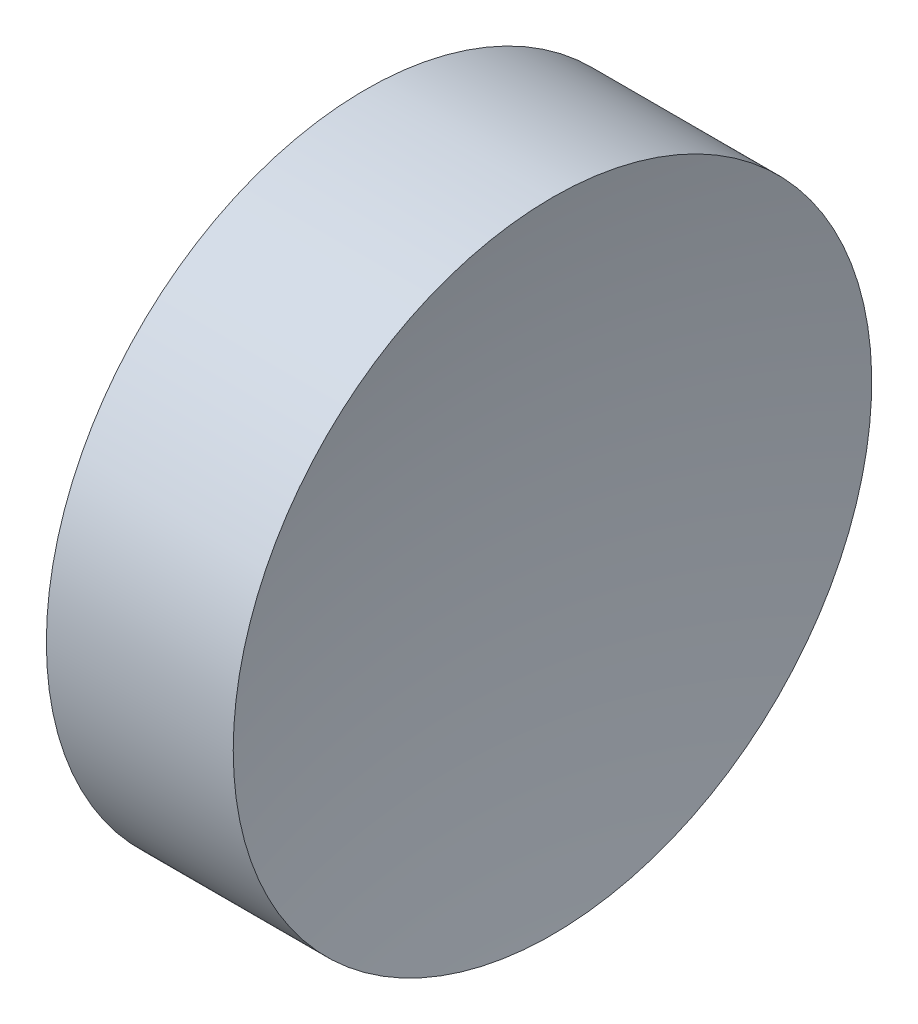
from build123d import *


with BuildPart() as part:
    # 草图1 → 旋转1 (revolve)
    with BuildSketch(Plane.XY):
        with BuildLine():
            Line((115.092655535, 69.378021123), (115.092655535, 81.878021123))
            Line((115.092655535, 81.878021123), (122.409182578, 81.878021123))
            ThreePointArc((122.409182578, 81.878021123), (121.422695024, 75.662590389), (121.09265555, 69.378021123))
            Line((121.09265555, 69.378021123), (115.092655535, 69.378021123))
        make_face()
    revolve(axis=Axis((108.985143002, 69.378021123, 0), (1, 0, 0)))


solid = part.part
